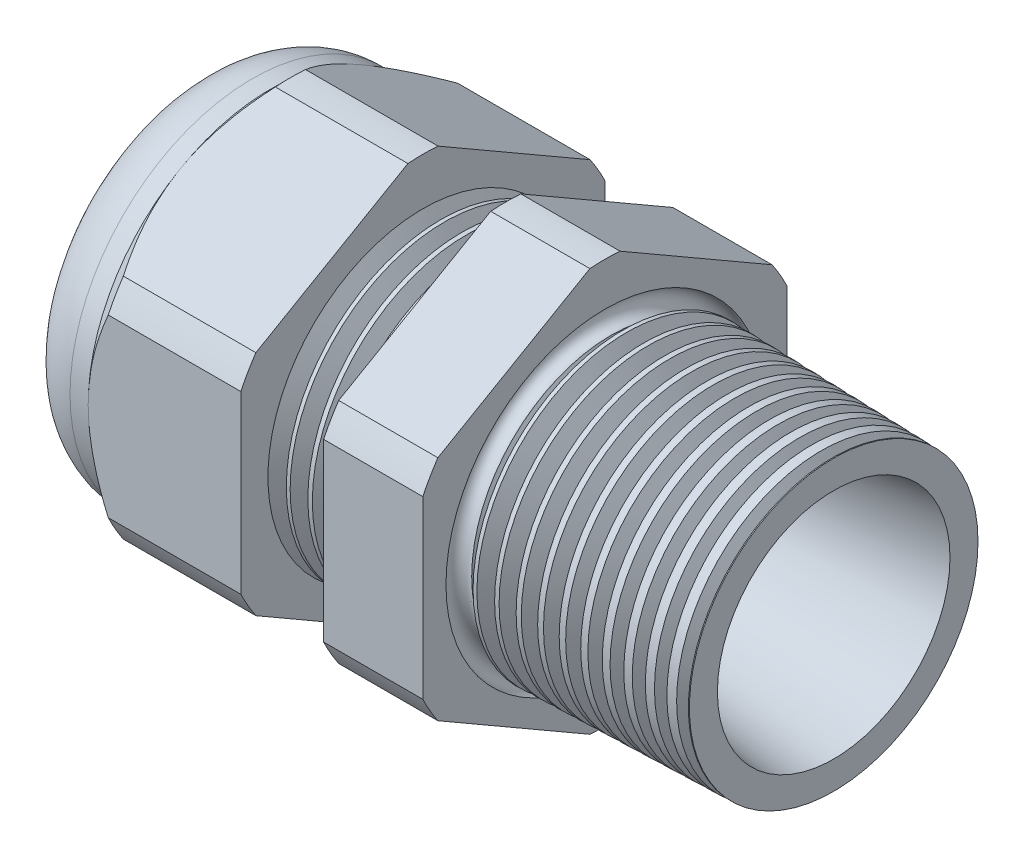
from build123d import *

# Parameters (mm, degrees)
LPATTERN6_COUNT    = 4
LPATTERN6_PITCH    = 1.397
LPATTERN7_COUNT    = 11
LPATTERN7_PITCH    = 1.397
SKETCH12_OUTSIDE_W = 65.648
SKETCH12_OUTSIDE_H = 65.648
CUT_EXTRUDE2_DEPTH = 37.91
FILLET4_R          = 3.81
SKETCH19_OUTSIDE_W = 40.884
SKETCH19_OUTSIDE_H = 43.51
SKETCH19_OUTSIDE_R = 11.938
CUT_EXTRUDE3_DEPTH = 1.999996
CUT_EXTRUDE3_DRAFT = -45
SKETCH28_R         = 0.6985


with BuildPart() as part:
    # Sketch10 → Revolve2 (revolve)
    with BuildSketch(Plane.XY, mode=Mode.PRIVATE) as revolve2_sk:
        Polygon((-29.798, 4.445), (-19.798, 4.445), (7.112, 7.62), (7.112, 9.455336851), (-7.874, 9.847759071), (-7.874, 23.876), (-14.374, 23.876), (-14.374, 10.017967561), (-19.798, 10.16), (-19.798, 23.876), (-29.798, 23.876), (-29.798, 11.938), (-34.798, 11.938), (-34.798, 7.62), (-29.798, 7.62), align=None)
    revolve(revolve2_sk.sketch.rotate(Axis((0, 0, 0), (-1, 0, 0)), 90), axis=Axis((0, 0, 0), (-1, 0, 0)))  # turned: the seam where the file's is

    # Sketch26 → Cut-Revolve1 (revolve, cut)
    with BuildSketch(Plane.XY, mode=Mode.PRIVATE) as cut_revolve1_sk:
        Polygon((-19.798, 10.16), (-18.625226271, 10.129289839), (-19.238208915, 9.128993077), align=None)
    cut_revolve1 = revolve(cut_revolve1_sk.sketch.rotate(Axis((0, 0, 0), (-1, 0, 0)), 90), axis=Axis((0, 0, 0), (-1, 0, 0)), mode=Mode.SUBTRACT)  # turned: the seam where the file's is

    # LPattern6: Cut-Revolve1 ×4
    with Locations(*[(i * LPATTERN6_PITCH, 0, 0) for i in range(1, LPATTERN6_COUNT)]):
        add(cut_revolve1, mode=Mode.SUBTRACT)

    # Sketch27 → Cut-Revolve2 (revolve, cut)
    with BuildSketch(Plane.XY, mode=Mode.PRIVATE) as cut_revolve2_sk:
        Polygon((-7.874, 9.847759071), (-6.701226271, 9.81704891), (-7.314208915, 8.816752149), align=None)
    cut_revolve2 = revolve(cut_revolve2_sk.sketch.rotate(Axis((0, 0, 0), (-1, 0, 0)), 90), axis=Axis((0, 0, 0), (-1, 0, 0)), mode=Mode.SUBTRACT)  # turned: the seam where the file's is

    # LPattern7: Cut-Revolve2 ×11
    with Locations(*[(i * LPATTERN7_PITCH, 0, 0) for i in range(1, LPATTERN7_COUNT)]):
        add(cut_revolve2, mode=Mode.SUBTRACT)

    # Sketch12 outside → Cut-Extrude2 (cut, through all)
    with BuildSketch(Plane.ZY.offset(29.798)):
        Rectangle(SKETCH12_OUTSIDE_W, SKETCH12_OUTSIDE_H)
        with BuildLine():
            Line((-0.98819228, 13.214281948), (-10.94980772, 7.462940592))
            ThreePointArc((-10.94980772, 7.462940592), (-11.47585851, 6.62559), (-11.938, 5.751341356))
            Line((-11.938, 5.751341356), (-11.938, -5.751341356))
            ThreePointArc((-11.938, -5.751341356), (-11.47585851, -6.62559), (-10.94980772, -7.462940592))
            Line((-10.94980772, -7.462940592), (-0.98819228, -13.214281948))
            ThreePointArc((-0.98819228, -13.214281948), (0, -13.25118), (0.98819228, -13.214281948))
            Line((0.98819228, -13.214281948), (10.94980772, -7.462940592))
            ThreePointArc((10.94980772, -7.462940592), (11.47585851, -6.62559), (11.938, -5.751341356))
            Line((11.938, -5.751341356), (11.938, 5.751341356))
            ThreePointArc((11.938, 5.751341356), (11.47585851, 6.62559), (10.94980772, 7.462940592))
            Line((10.94980772, 7.462940592), (0.98819228, 13.214281948))
            ThreePointArc((0.98819228, 13.214281948), (0, 13.25118), (-0.98819228, 13.214281948))
        make_face(mode=Mode.SUBTRACT)
    extrude(amount=-CUT_EXTRUDE2_DEPTH, mode=Mode.SUBTRACT)

    # Fillet4
    fillet4_edges = [part.edges().sort_by_distance(p)[0] for p in [
        (-34.798, 0, 11.938),
    ]]
    fillet(fillet4_edges, radius=FILLET4_R)


with BuildPart() as body_2:
    # Sketch30 → Revolve8 (revolve)
    with BuildSketch(Plane.XY, mode=Mode.PRIVATE) as revolve8_sk:
        with BuildLine():
            Line((-33.8074, 7.62), (-29.798, 7.62))
            Line((-29.798, 7.62), (-29.798, 4.445))
            Line((-29.798, 4.445), (-34.036, 4.445))
            Line((-34.036, 4.445), (-34.036, 7.3914))
            ThreePointArc((-34.036, 7.3914), (-33.96904461, 7.55304461), (-33.8074, 7.62))
        make_face()
    revolve(revolve8_sk.sketch.rotate(Axis((0, 0, 0), (-1, 0, 0)), 90), axis=Axis((0, 0, 0), (-1, 0, 0)))  # turned: the seam where the file's is


with BuildPart() as cut_extrude3_tool:
    # Sketch19 outside → Cut-Extrude3 (with draft: the straight prism first)
    with BuildSketch(Plane.ZY.offset(29.798)):
        Rectangle(SKETCH19_OUTSIDE_W, SKETCH19_OUTSIDE_H)
        Circle(SKETCH19_OUTSIDE_R, mode=Mode.SUBTRACT)
    extrude(amount=-CUT_EXTRUDE3_DEPTH)
    # Cut-Extrude3: the draft: its side faces are tilted about the plane it starts from
    cut_extrude3_sides = [cut_extrude3_tool.faces().sort_by_distance(p)[0] for p in [
        (-28.798002, -21.755, 0),
        (-28.798002, 0, 20.442),
        (-28.798002, 21.755, 0),
        (-28.798002, 0, -20.442),
        (-28.798002, 0, -11.938),
    ]]
    draft(cut_extrude3_sides, Plane.ZY.offset(29.798), CUT_EXTRUDE3_DRAFT)


with BuildPart() as part_1:
    add(part.part)

    # Cut-Extrude3: cut by cut_extrude3_tool
    add(cut_extrude3_tool.part, mode=Mode.SUBTRACT)

    # Sketch28 → Cut-Revolve3 (revolve, cut)
    with BuildSketch(Plane.XY, mode=Mode.PRIVATE) as cut_revolve3_sk:
        with Locations((-7.8486, -9.720759071)):
            Circle(SKETCH28_R)
    revolve(cut_revolve3_sk.sketch.rotate(Axis((7.112, 0, 0), (-1, 0, 0)), 90), axis=Axis((7.112, 0, 0), (-1, 0, 0)), mode=Mode.SUBTRACT)  # turned: the seam where the file's is


solid = Compound([body_2.part, part_1.part])
